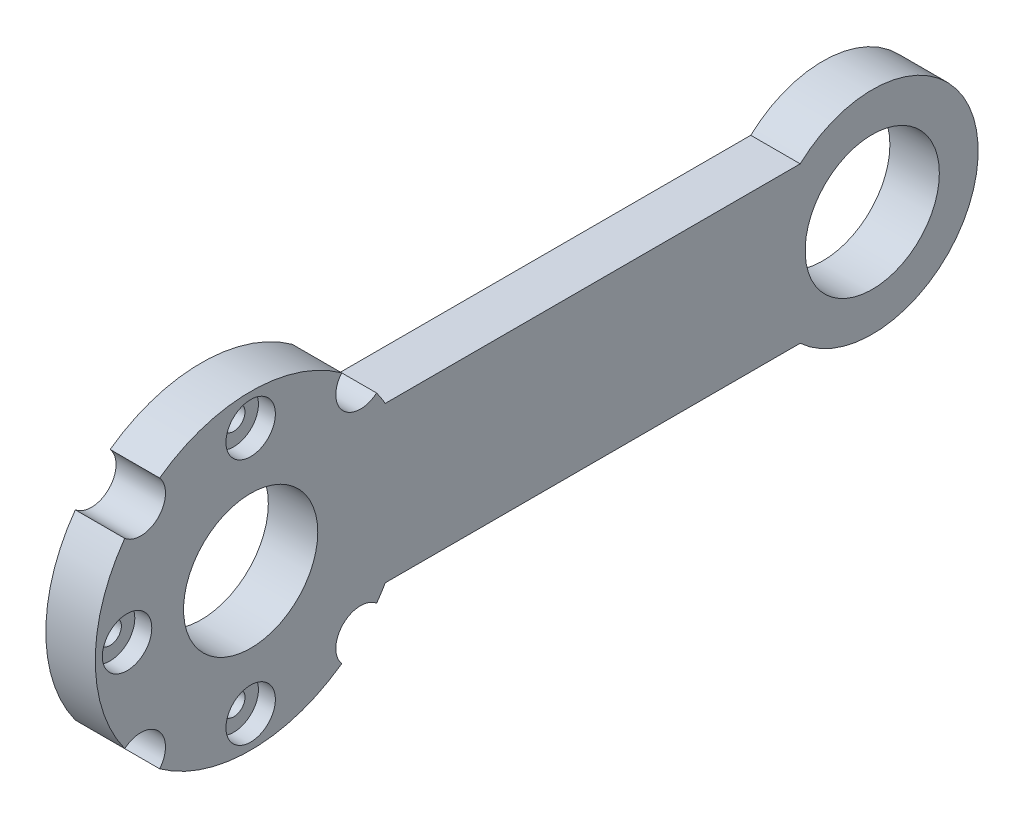
from build123d import *

# Parameters (mm, degrees)
BOSS_EXTRUDE1_DEPTH                              = 7
CBORE_FOR_M3_PAN_HEAD_MACHINE_SCREW1_D           = 3.2
CBORE_FOR_M3_PAN_HEAD_MACHINE_SCREW1_CBORE_D     = 7
CBORE_FOR_M3_PAN_HEAD_MACHINE_SCREW1_CBORE_DEPTH = 2.4
SKETCH5_R                                        = 9.5
CUT_EXTRUDE1_DEPTH                               = 1
CUT_EXTRUDE1_DEPTH_BACK                          = 8
SKETCH6_R                                        = 3.5
CUT_EXTRUDE2_DEPTH                               = 1
CUT_EXTRUDE2_DEPTH_BACK                          = 8
SKETCH7_R                                        = 9.5
CUT_EXTRUDE3_DEPTH                               = 1
CUT_EXTRUDE3_DEPTH_BACK                          = 8


with BuildPart() as part:
    # Sketch1 → Boss-Extrude1 (new body)
    with BuildSketch(Plane(origin=(0, 0, 0), x_dir=(0, 0, -1), z_dir=(1, 0, 0))):
        with BuildLine():
            ThreePointArc((77.801960973, 11), (73, 0), (77.801960973, -11))
            Line((77.801960973, -11), (88, -11))
            Line((88, -11), (88, 11))
            Line((88, 11), (77.801960973, 11))
        make_face()
        with BuildLine():
            Line((88, -11), (77.801960973, -11))
            ThreePointArc((77.801960973, -11), (94.001225483, -13.747192175), (103, 0))
            ThreePointArc((103, 0), (94.001225483, 13.747192175), (77.801960973, 11))
            Line((77.801960973, 11), (88, 11))
            Line((88, 11), (88, -11))
        make_face()
        with BuildLine():
            ThreePointArc((22, 0), (21.250368178, -5.694018992), (19.052558883, -11))
            Line((19.052558883, -11), (77.801960973, -11))
            ThreePointArc((77.801960973, -11), (73, 0), (77.801960973, 11))
            Line((77.801960973, 11), (19.052558883, 11))
            ThreePointArc((19.052558883, 11), (21.250368178, 5.694018992), (22, 0))
        make_face()
        with BuildLine():
            Line((0, 11), (0, -11))
            Line((0, -11), (19.052558883, -11))
            ThreePointArc((19.052558883, -11), (21.250368178, -5.694018992), (22, 0))
            ThreePointArc((22, 0), (21.250368178, 5.694018992), (19.052558883, 11))
            Line((19.052558883, 11), (0, 11))
        make_face()
        with BuildLine():
            Line((19.052558883, -11), (0, -11))
            Line((0, -11), (0, 11))
            Line((0, 11), (19.052558883, 11))
            ThreePointArc((19.052558883, 11), (-22, 0), (19.052558883, -11))
        make_face()
    extrude(amount=BOSS_EXTRUDE1_DEPTH)

    # CBORE for M3 Pan Head Machine Screw1 (through all)
    with Locations(Plane(origin=(7, 0, 0), x_dir=(0, 0, -1), z_dir=(1, 0, 0))):
        with Locations((0, -17.5), (0, 17.5), (-17.5, 0)):
            CounterBoreHole(CBORE_FOR_M3_PAN_HEAD_MACHINE_SCREW1_D / 2, CBORE_FOR_M3_PAN_HEAD_MACHINE_SCREW1_CBORE_D / 2, CBORE_FOR_M3_PAN_HEAD_MACHINE_SCREW1_CBORE_DEPTH)

    # Sketch5 → Cut-Extrude1 (cut, two sides)
    with BuildSketch(Plane(origin=(7, 0, 0), x_dir=(0, 0, -1), z_dir=(1, 0, 0))) as cut_extrude1_sk:
        Circle(SKETCH5_R)
    extrude(amount=CUT_EXTRUDE1_DEPTH, mode=Mode.SUBTRACT)
    extrude(cut_extrude1_sk.sketch, amount=-CUT_EXTRUDE1_DEPTH_BACK, mode=Mode.SUBTRACT)

    # Sketch6 → Cut-Extrude2 (cut, two sides)
    with BuildSketch(Plane(origin=(7, 0, 0), x_dir=(0, 0, -1), z_dir=(1, 0, 0))) as cut_extrude2_sk:
        with Locations((15.556349186, 15.556349186)):
            Circle(SKETCH6_R)
        with Locations((-15.556349186, 15.556349186)):
            Circle(SKETCH6_R)
        with Locations((-15.556349186, -15.556349186)):
            Circle(SKETCH6_R)
        with Locations((15.556349186, -15.556349186)):
            Circle(SKETCH6_R)
    extrude(amount=CUT_EXTRUDE2_DEPTH, mode=Mode.SUBTRACT)
    extrude(cut_extrude2_sk.sketch, amount=-CUT_EXTRUDE2_DEPTH_BACK, mode=Mode.SUBTRACT)

    # Sketch7 → Cut-Extrude3 (cut, two sides)
    with BuildSketch(Plane(origin=(7, 0, 0), x_dir=(0, 0, -1), z_dir=(1, 0, 0))) as cut_extrude3_sk:
        with Locations((88, 0)):
            Circle(SKETCH7_R)
    extrude(amount=CUT_EXTRUDE3_DEPTH, mode=Mode.SUBTRACT)
    extrude(cut_extrude3_sk.sketch, amount=-CUT_EXTRUDE3_DEPTH_BACK, mode=Mode.SUBTRACT)


solid = part.part
